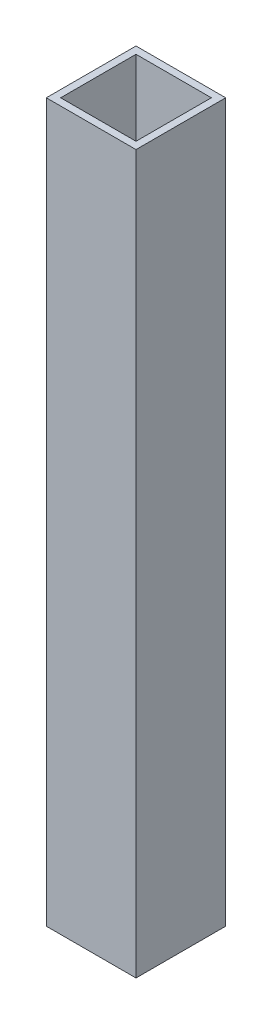
from build123d import *

# Parameters (mm, degrees)
SKETCH1_W           = 25
SKETCH1_H           = 25
SKETCH1_W_2         = 21
SKETCH1_H_2         = 21
BOSS_EXTRUDE1_DEPTH = 200


with BuildPart() as part:
    # Sketch1 → Boss-Extrude1 (new body)
    with BuildSketch(Plane(origin=(0, 0, 0), x_dir=(1, 0, 0), z_dir=(0, 1, 0))):
        Rectangle(SKETCH1_W, SKETCH1_H)
        Rectangle(SKETCH1_W_2, SKETCH1_H_2, mode=Mode.SUBTRACT)
    extrude(amount=BOSS_EXTRUDE1_DEPTH)


solid = part.part
